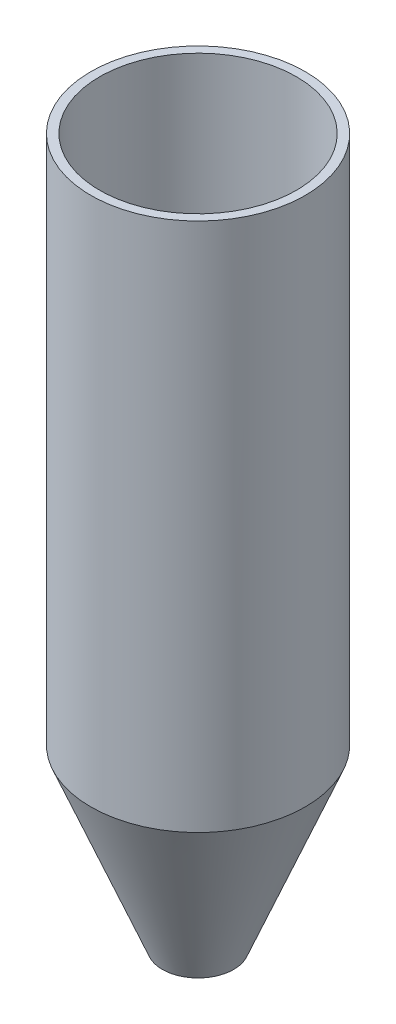
from build123d import *

# Parameters (mm, degrees)
SKETCH2_R          = 0.405
CUT_EXTRUDE1_DEPTH = 10


with BuildPart() as part:
    # Sketch1 → Revolve1 (revolve)
    with BuildSketch(Plane.XY):
        Polygon((-1.215, 9), (-1.215, 3), (0, 0), (0, 0.266395038), (-1.115, 3.019481457), (-1.115, 9), align=None)
    revolve(axis=Axis((0, 0, 0), (0, 1, 0)))

    # Sketch2 → Cut-Extrude1 (cut)
    with BuildSketch(Plane(origin=(0, 0, 0), x_dir=(1, 0, 0), z_dir=(0, 1, 0))):
        Circle(SKETCH2_R)
    extrude(amount=CUT_EXTRUDE1_DEPTH, mode=Mode.SUBTRACT)


solid = part.part
